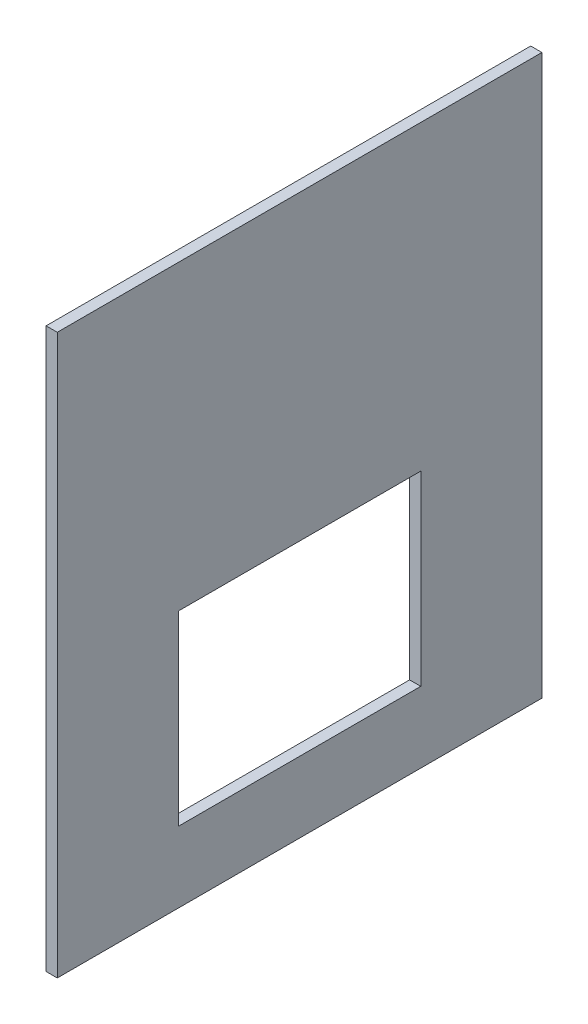
from build123d import *

# Parameters (mm, degrees)
SKETCH1_W           = 130
SKETCH1_H           = 150
SKETCH1_W_2         = 65
SKETCH1_H_2         = 50
BOSS_EXTRUDE1_DEPTH = 3


with BuildPart() as part:
    # Sketch1 → Boss-Extrude1 (new body)
    with BuildSketch(Plane(origin=(0, 0, 0), x_dir=(0, 0, -1), z_dir=(1, 0, 0))):
        with Locations((65, 75)):
            Rectangle(SKETCH1_W, SKETCH1_H)
        with Locations((65, 44)):
            Rectangle(SKETCH1_W_2, SKETCH1_H_2, mode=Mode.SUBTRACT)
    extrude(amount=BOSS_EXTRUDE1_DEPTH)


solid = part.part
